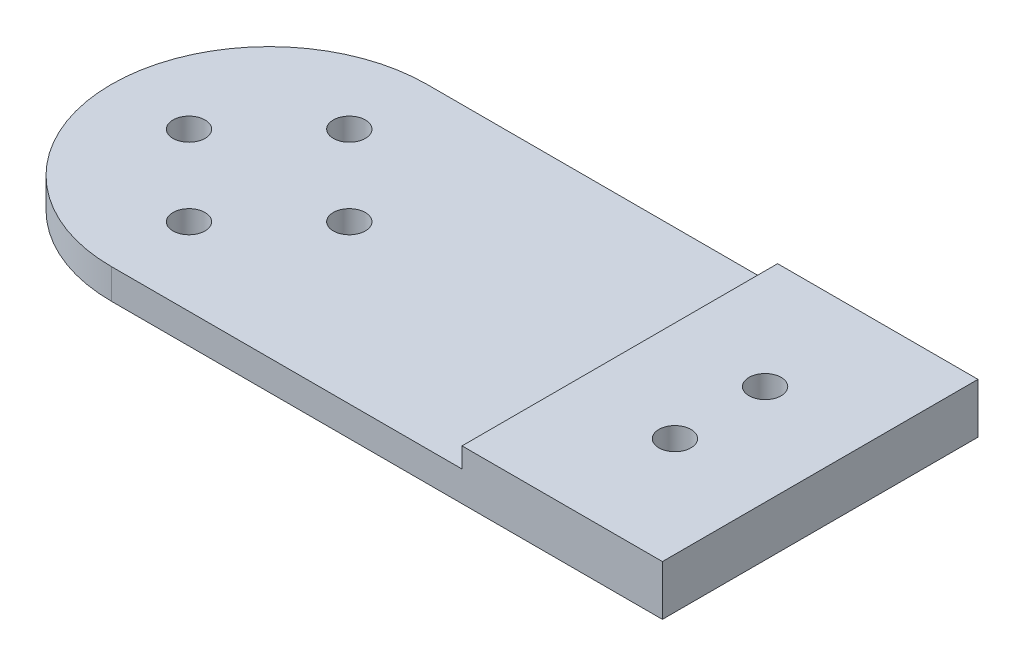
from build123d import *

# Parameters (mm, degrees)
SKETCH_1_R          = 15.75
SKETCH_1_R_2        = 1.6
EXTRUDE_1_DEPTH     = 3
EXTRUDE_2_DEPTH     = 3
SKETCH_3_W          = 20
SKETCH_3_H          = 31.5
EXTRUDE_3_DEPTH     = 5
SKETCH_4_R          = 1.6
CUT_EXTRUDE_1_DEPTH = 10


with BuildPart() as part:
    # 草图1 → 凸台-拉伸1 (new body)
    with BuildSketch(Plane(origin=(0, 0, 0), x_dir=(1, 0, 0), z_dir=(0, 1, 0))):
        Circle(SKETCH_1_R)
        with Locations((0, 8)):
            Circle(SKETCH_1_R_2, mode=Mode.SUBTRACT)
        with Locations((8, 0)):
            Circle(SKETCH_1_R_2, mode=Mode.SUBTRACT)
        with Locations((0, -8)):
            Circle(SKETCH_1_R_2, mode=Mode.SUBTRACT)
        with Locations((-8, 0)):
            Circle(SKETCH_1_R_2, mode=Mode.SUBTRACT)
    extrude(amount=EXTRUDE_1_DEPTH)

    # 草图2 → 凸台-拉伸2 (add)
    with BuildSketch(Plane.XZ):
        with BuildLine():
            Line((0, 15.75), (55, 15.75))
            Line((55, 15.75), (55, -15.75))
            Line((55, -15.75), (0, -15.75))
            ThreePointArc((0, -15.75), (15.75, 0), (0, 15.75))
        make_face()
    extrude(amount=-EXTRUDE_2_DEPTH)

    # 草图3 → 凸台-拉伸3 (add)
    with BuildSketch(Plane.XZ):
        with Locations((45, 0)):
            Rectangle(SKETCH_3_W, SKETCH_3_H)
    extrude(amount=-EXTRUDE_3_DEPTH)

    # 草图4 → 切除-拉伸1 (cut)
    with BuildSketch(Plane(origin=(0, 5, 0), x_dir=(1, 0, 0), z_dir=(0, 1, 0))):
        with Locations((45, 4.5)):
            Circle(SKETCH_4_R)
        with Locations((45, -4.5)):
            Circle(SKETCH_4_R)
    extrude(amount=-CUT_EXTRUDE_1_DEPTH, mode=Mode.SUBTRACT)


solid = part.part
